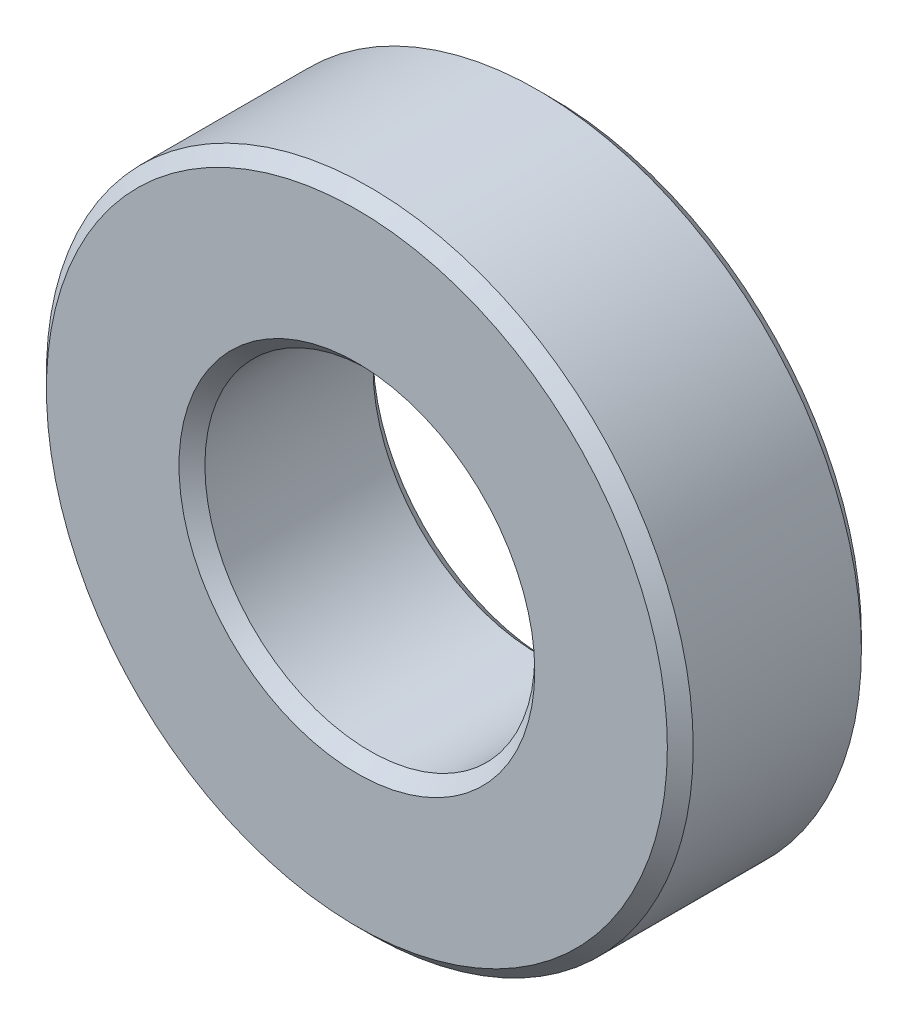
from build123d import *

# Parameters (mm, degrees)
SKETCH1_R           = 5
SKETCH1_R_2         = 2.55
BOSS_EXTRUDE1_DEPTH = 3
CHAMFER1_SIZE       = 0.2


with BuildPart() as part:
    # Sketch1 → Boss-Extrude1 (new body)
    with BuildSketch(Plane.XY):
        Circle(SKETCH1_R)
        Circle(SKETCH1_R_2, mode=Mode.SUBTRACT)
    extrude(amount=BOSS_EXTRUDE1_DEPTH)

    # Chamfer1
    chamfer1_edges = [part.edges().sort_by_distance(p)[0] for p in [
        (-5, 0, 0),
        (-5, 0, 3),
        (-2.55, 0, 0),
        (-2.55, 0, 3),
    ]]
    chamfer(chamfer1_edges, length=CHAMFER1_SIZE)


solid = part.part
